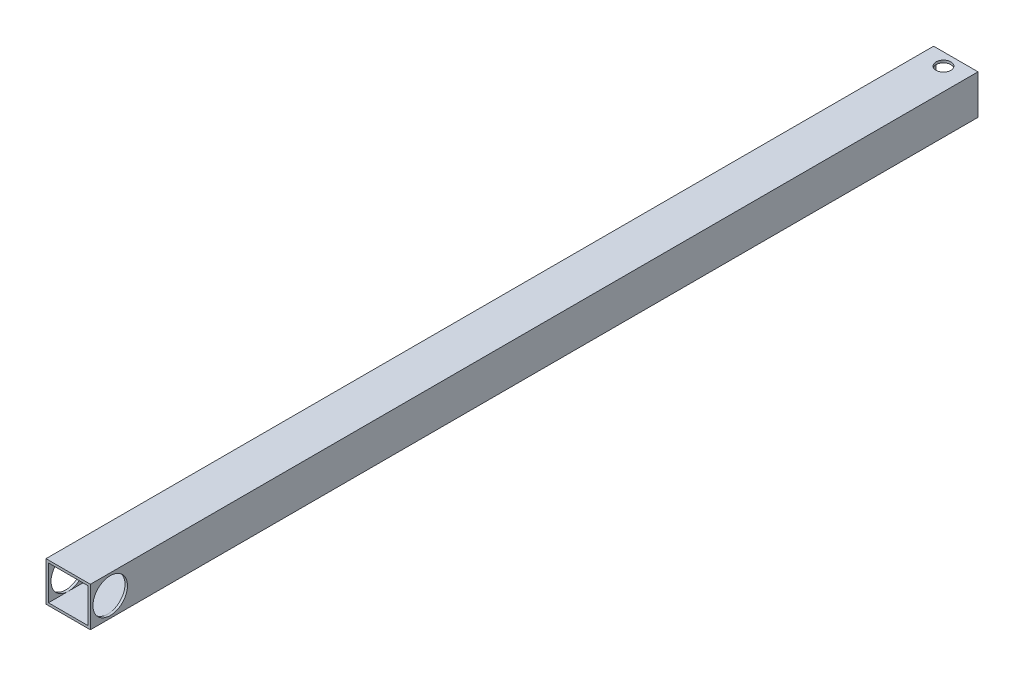
from build123d import *

# Parameters (mm, degrees)
SKETCH2_W           = 9
SKETCH2_H           = 8
BOSS_EXTRUDE1_DEPTH = 180
SKETCH3_R           = 1.5
CUT_EXTRUDE1_DEPTH  = 9
SKETCH4_W           = 8
SKETCH4_H           = 7
CUT_EXTRUDE2_DEPTH  = 181
SKETCH5_R           = 3.5
CUT_EXTRUDE3_DEPTH  = 10


with BuildPart() as part:
    # Sketch2 → Boss-Extrude1 (new body)
    with BuildSketch(Plane.XY):
        Rectangle(SKETCH2_W, SKETCH2_H)
    extrude(amount=BOSS_EXTRUDE1_DEPTH)

    # Sketch3 → Cut-Extrude1 (cut, through all)
    with BuildSketch(Plane(origin=(0, 4, 0), x_dir=(1, 0, 0), z_dir=(0, 1, 0))):
        with Locations((0, -2.500384155)):
            Circle(SKETCH3_R)
    extrude(amount=-CUT_EXTRUDE1_DEPTH, mode=Mode.SUBTRACT)

    # Sketch4 → Cut-Extrude2 (cut, through all)
    with BuildSketch(Plane.XY):
        Rectangle(SKETCH4_W, SKETCH4_H)
    extrude(amount=CUT_EXTRUDE2_DEPTH, mode=Mode.SUBTRACT)

    # Sketch5 → Cut-Extrude3 (cut, through all)
    with BuildSketch(Plane(origin=(4.5, 0, 0), x_dir=(0, 0, -1), z_dir=(1, 0, 0))):
        with Locations((-175.980500671, 0)):
            Circle(SKETCH5_R)
    extrude(amount=-CUT_EXTRUDE3_DEPTH, mode=Mode.SUBTRACT)


solid = part.part
